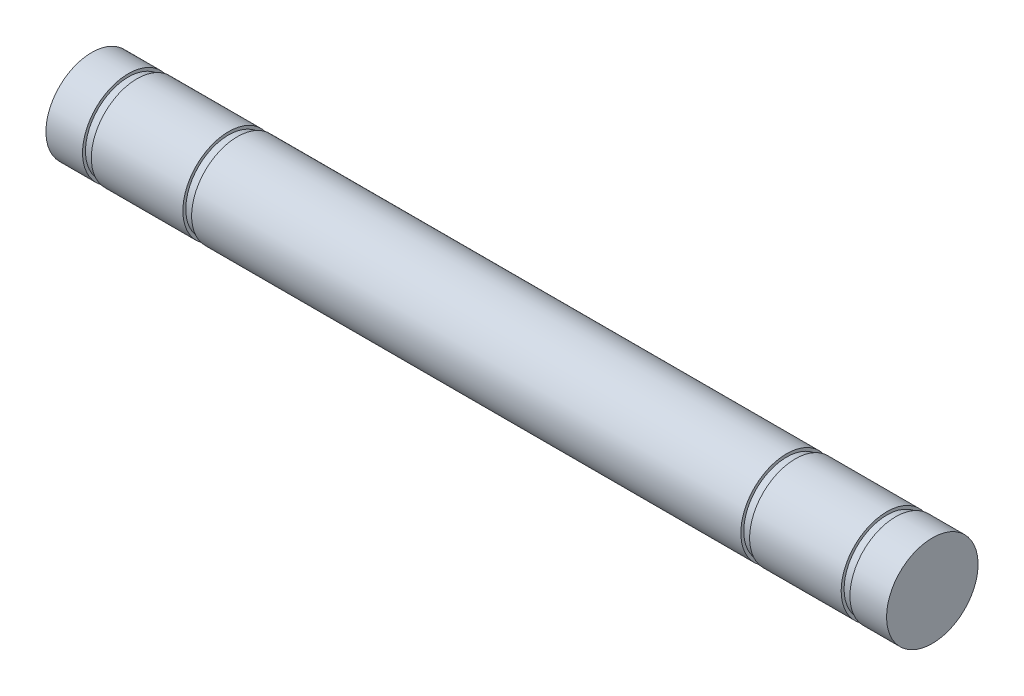
from build123d import *

# Parameters (mm, degrees)
SKETCH2_R               = 1.5875
EXTRUDE1_DEPTH          = 25.4
EXTRUDE1_DEPTH_BACK     = 25.4
CHAMFER1_SIZE           = 0.3175
SKETCH3_OUTSIDE_W       = 15.376
SKETCH3_OUTSIDE_H       = 15.376
SKETCH3_OUTSIDE_R       = 1.4859
CUT_EXTRUDE1_DEPTH      = 0.3048
SKETCH4_OUTSIDE_W       = 15.376
SKETCH4_OUTSIDE_H       = 15.376
SKETCH4_OUTSIDE_R       = 1.4859
CUT_EXTRUDE2_DEPTH      = 0.3048
CUT_EXTRUDE4_START      = -3.175
SKETCH6_OUTSIDE_W       = 15.376
SKETCH6_OUTSIDE_H       = 15.376
SKETCH6_OUTSIDE_R       = 1.4859
CUT_EXTRUDE4_DEPTH      = 0.3048
CUT_EXTRUDE5_START      = -3.175
SKETCH8_OUTSIDE_W       = 15.376
SKETCH8_OUTSIDE_H       = 15.376
SKETCH8_OUTSIDE_R       = 1.4859
CUT_EXTRUDE5_DEPTH      = 0.3048
SKETCH5_W               = 20.3454
SKETCH5_H               = 6.35
SKETCH5_W_2             = 1.2954
CUT_EXTRUDE3_DEPTH      = 2.5875
CUT_EXTRUDE3_DEPTH_BACK = 2.5875


with BuildPart() as part:
    # Sketch2 → Extrude1 (new body, two sides)
    with BuildSketch(Plane(origin=(0, 0, 0), x_dir=(0, 0, -1), z_dir=(1, 0, 0))) as extrude1_sk:
        Circle(SKETCH2_R)
    extrude(amount=EXTRUDE1_DEPTH)
    extrude(extrude1_sk.sketch, amount=-EXTRUDE1_DEPTH_BACK)

    # Chamfer1
    chamfer1_edges = [part.edges().sort_by_distance(p)[0] for p in [
        (-25.4, 0, 1.5875),
        (25.4, 0, 1.5875),
    ]]
    chamfer(chamfer1_edges, length=CHAMFER1_SIZE)

    # Sketch3 outside → Cut-Extrude1 (cut)
    with BuildSketch(Plane(origin=(19.05, 0, 0), x_dir=(0, 0, -1), z_dir=(1, 0, 0))):
        Rectangle(SKETCH3_OUTSIDE_W, SKETCH3_OUTSIDE_H)
        Circle(SKETCH3_OUTSIDE_R, mode=Mode.SUBTRACT)
    extrude(amount=CUT_EXTRUDE1_DEPTH, mode=Mode.SUBTRACT)

    # Sketch4 outside → Cut-Extrude2 (cut)
    with BuildSketch(Plane(origin=(0, 0, 0), x_dir=(0, 0, -1), z_dir=(1, 0, 0))):
        Rectangle(SKETCH4_OUTSIDE_W, SKETCH4_OUTSIDE_H)
        Circle(SKETCH4_OUTSIDE_R, mode=Mode.SUBTRACT)
    extrude(amount=-CUT_EXTRUDE2_DEPTH, mode=Mode.SUBTRACT)

    # Sketch6 outside → Cut-Extrude4 (cut)
    with BuildSketch(Plane.ZY.offset(-19.3548).offset(CUT_EXTRUDE4_START)):
        Rectangle(SKETCH6_OUTSIDE_W, SKETCH6_OUTSIDE_H)
        Circle(SKETCH6_OUTSIDE_R, mode=Mode.SUBTRACT)
    extrude(amount=-CUT_EXTRUDE4_DEPTH, mode=Mode.SUBTRACT)

    # Sketch8 outside → Cut-Extrude5 (cut)
    with BuildSketch(Plane(origin=(-0.3048, 0, 0), x_dir=(0, 0, -1), z_dir=(1, 0, 0)).offset(CUT_EXTRUDE5_START)):
        Rectangle(SKETCH8_OUTSIDE_W, SKETCH8_OUTSIDE_H)
        Circle(SKETCH8_OUTSIDE_R, mode=Mode.SUBTRACT)
    extrude(amount=-CUT_EXTRUDE5_DEPTH, mode=Mode.SUBTRACT)

    # Sketch5 → Cut-Extrude3 (cut, two sides)
    with BuildSketch(Plane.XY) as cut_extrude3_sk:
        with Locations((-15.2273, 0)):
            Rectangle(SKETCH5_W, SKETCH5_H)
        with Locations((24.7523, 0)):
            Rectangle(SKETCH5_W_2, SKETCH5_H)
    extrude(amount=CUT_EXTRUDE3_DEPTH, mode=Mode.SUBTRACT)
    extrude(cut_extrude3_sk.sketch, amount=-CUT_EXTRUDE3_DEPTH_BACK, mode=Mode.SUBTRACT)


solid = part.part
